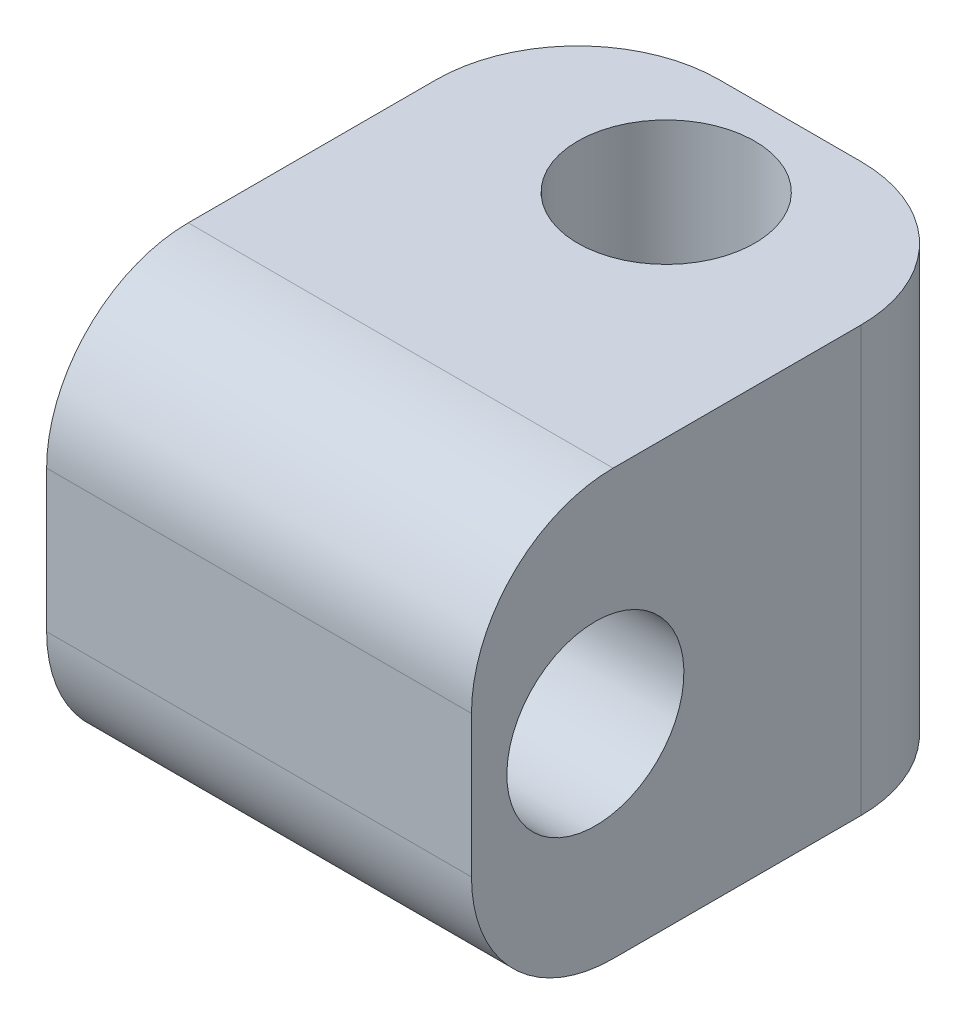
from build123d import *

# Parameters (mm, degrees)
SKETCH1_W          = 12
SKETCH1_H          = 12
EXTRUDE1_DEPTH     = 7.5
SKETCH2_R          = 2.5
CUT_EXTRUDE1_DEPTH = 13
SKETCH3_R          = 2.5
CUT_EXTRUDE2_DEPTH = 13
FILLET1_R          = 4


with BuildPart() as part:
    # Sketch1 → Extrude1 (new body, symmetric)
    with BuildSketch(Plane.XY):
        Rectangle(SKETCH1_W, SKETCH1_H)
    extrude(amount=EXTRUDE1_DEPTH, both=True)

    # Sketch2 → Cut-Extrude1 (cut, through all)
    with BuildSketch(Plane(origin=(0, 6, 0), x_dir=(1, 0, 0), z_dir=(0, 1, 0))):
        with Locations((0, 4)):
            Circle(SKETCH2_R)
    extrude(amount=-CUT_EXTRUDE1_DEPTH, mode=Mode.SUBTRACT)

    # Sketch3 → Cut-Extrude2 (cut, through all)
    with BuildSketch(Plane(origin=(6, 0, 0), x_dir=(0, 0, -1), z_dir=(1, 0, 0))):
        with Locations((-4, 0)):
            Circle(SKETCH3_R)
    extrude(amount=-CUT_EXTRUDE2_DEPTH, mode=Mode.SUBTRACT)

    # Fillet1
    fillet1_edges = [part.edges().sort_by_distance(p)[0] for p in [
        (0, 6, 7.5),
        (6, 0, -7.5),
        (-6, 0, -7.5),
        (0, -6, 7.5),
    ]]
    fillet(fillet1_edges, radius=FILLET1_R)


solid = part.part
